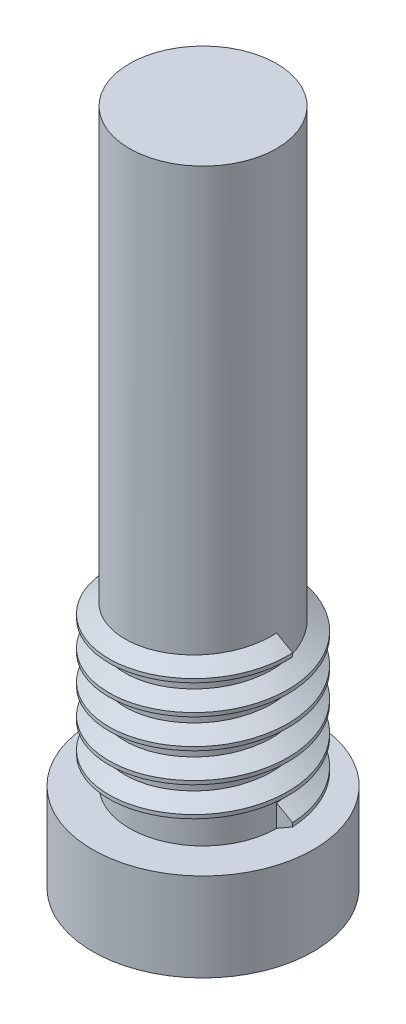
from build123d import *
from build123d.topology import SkipClean

# Parameters (mm, degrees)
SKETCH2_R           = 4.7625
BOSS_EXTRUDE1_DEPTH = 3.81
SKETCH3_R           = 3.175
BOSS_EXTRUDE2_DEPTH = 25.4
THREAD2_PITCH       = 1.27
THREAD2_HEIGHT      = 6.35
THREAD2_RADIUS      = 3.175
THREAD2_START_ANGLE = 90


with BuildPart() as part:
    # Sketch2 → Boss-Extrude1 (new body)
    with BuildSketch(Plane(origin=(0, 0, 0), x_dir=(1, 0, 0), z_dir=(0, 1, 0))):
        with Locations(Location((0, 0, 0), (0, 0, 90))):
            Circle(SKETCH2_R)
    extrude(amount=BOSS_EXTRUDE1_DEPTH)

    # Sketch3 → Boss-Extrude2 (add)
    with BuildSketch(Plane(origin=(0, 3.81, 0), x_dir=(1, 0, 0), z_dir=(0, 1, 0))):
        with Locations(Location((0, 0, 0), (0, 0, 270))):
            Circle(SKETCH3_R)
    extrude(amount=BOSS_EXTRUDE2_DEPTH)

    # Thread2: sweep along a helix
    with SkipClean():  # the faces are left unmerged after this step: merging them gives an invalid solid
        with BuildLine() as thread2_path:
            add(Helix(THREAD2_PITCH, THREAD2_HEIGHT, THREAD2_RADIUS, center=(0, 3.81, 0), direction=(0, 1, 0), mode=Mode.PRIVATE).rotate(Axis((0, 3.81, 0), (0, 1, 0)), THREAD2_START_ANGLE))
        # Thread Profile2 → Thread2 (sweep)
        with BuildSketch(Plane(origin=(3.175, 3.81, 0), x_dir=(1, 0, 0), z_dir=(0, 0, 1))):
            Polygon((0, 0), (0.687407661, 0.396874998), (0.687407661, 0.555624998), (0, 0.952499997), align=None)
        sweep(path=thread2_path.line, is_frenet=True)


solid = part.part
